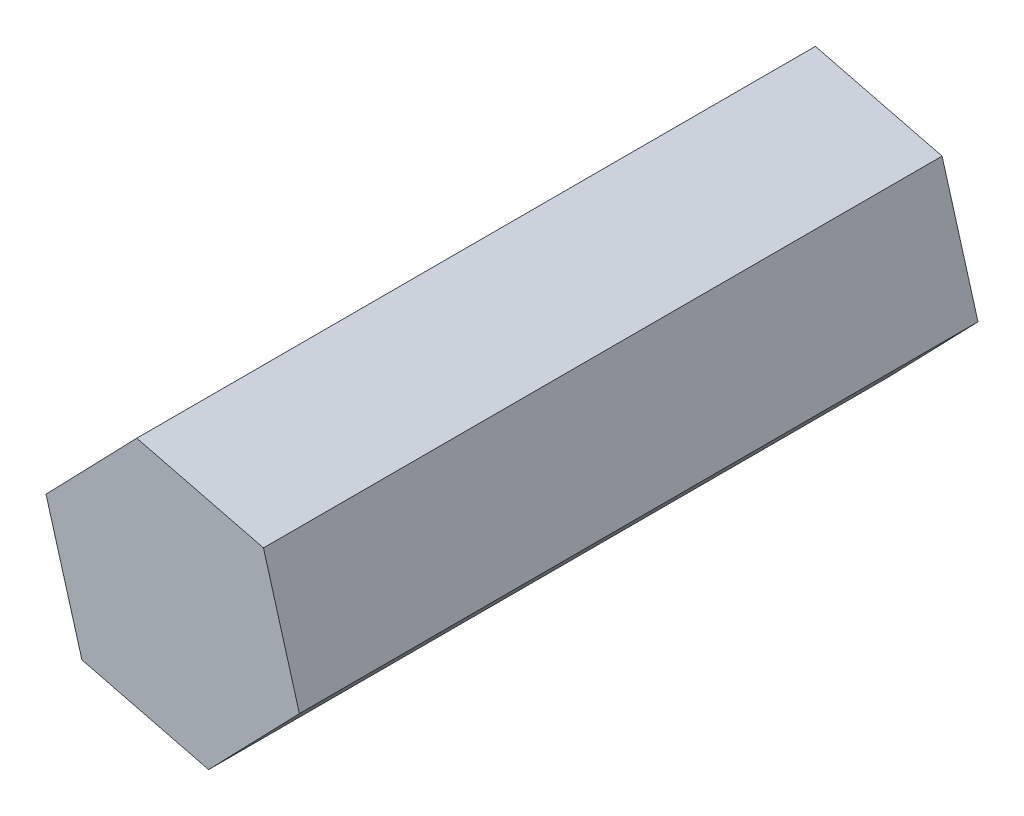
from build123d import *

# Parameters (mm, degrees)
BOSS_EXTRUDE1_DEPTH = 38.1
SKETCH2_R           = 1.822024131
CUT_EXTRUDE1_DEPTH  = 2.54


with BuildPart() as part:
    # Sketch1 → Boss-Extrude1 (new body)
    with BuildSketch(Plane.XY):
        Polygon((-7.113422827, 1.778355707), (-5.096812632, -5.271227023), (2.016610194, -7.049582729), (7.113422827, -1.778355707), (5.096812632, 5.271227023), (-2.016610194, 7.049582729), align=None)
    extrude(amount=BOSS_EXTRUDE1_DEPTH)

    # Sketch2 → Cut-Extrude1 (cut)
    with BuildSketch(Plane(origin=(0, 0, 0), x_dir=(-1, 0, 0), z_dir=(0, 0, -1))):
        Circle(SKETCH2_R)
    extrude(amount=-CUT_EXTRUDE1_DEPTH, mode=Mode.SUBTRACT)


solid = part.part
